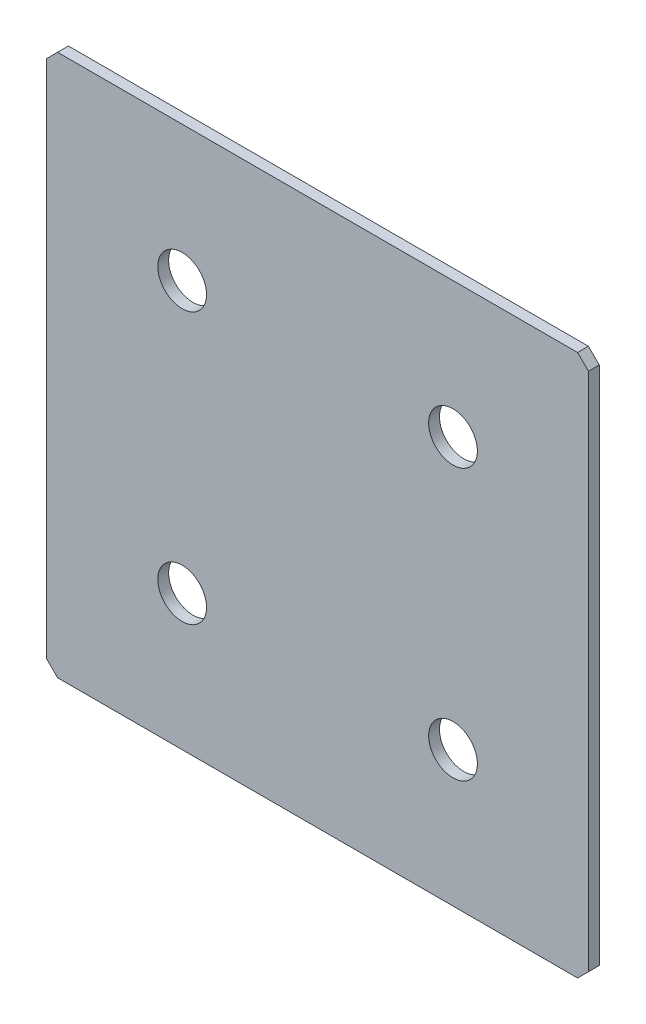
from build123d import *

# Parameters (mm, degrees)
SKETCH_1_W        = 100
SKETCH_1_H        = 100
EXTRUDE_1_DEPTH   = 2
CHAMFER_1_SIZE    = 2
HOLE_WIZARD_M81_D = 9


with BuildPart() as part:
    # Эскиз1 → Бобышка-Вытянуть1 (new body)
    with BuildSketch(Plane.XY):
        Rectangle(SKETCH_1_W, SKETCH_1_H)
    extrude(amount=EXTRUDE_1_DEPTH)

    # Фаска1
    chamfer_1_edges = [part.edges().sort_by_distance(p)[0] for p in [
        (50, -50, 1),
        (-50, -50, 1),
        (-50, 50, 1),
        (50, 50, 1),
    ]]
    chamfer(chamfer_1_edges, length=CHAMFER_1_SIZE)

    # Отверстие с зазором M81 (through all)
    with Locations(Plane.XY.offset(2)):
        with Locations((-25, 25), (25, 25), (-25, -25), (25, -25)):
            Hole(HOLE_WIZARD_M81_D / 2)


solid = part.part
